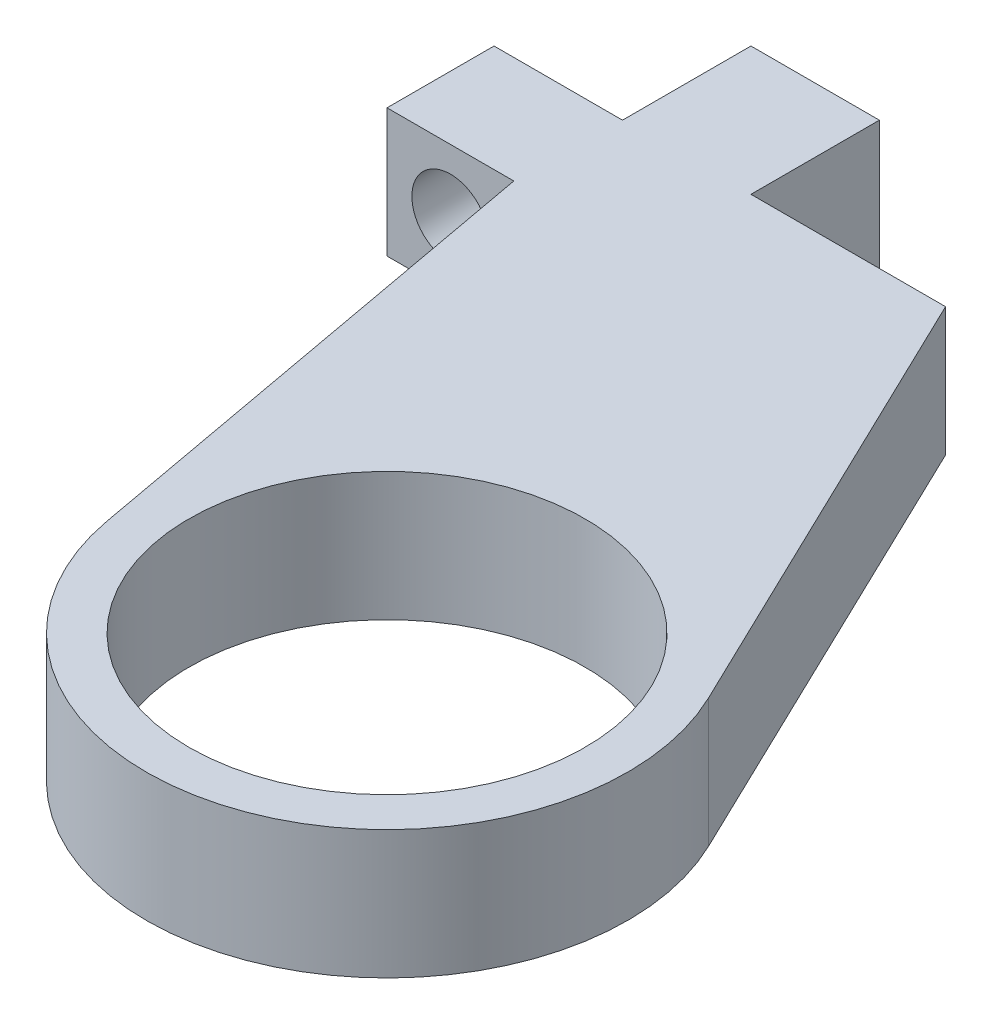
from build123d import *

# Parameters (mm, degrees)
SKETCH1_R           = 9.25
BOSS_EXTRUDE1_DEPTH = 6
SKETCH2_R           = 1.8
CUT_EXTRUDE1_DEPTH  = 12


with BuildPart() as part:
    # Sketch1 → Boss-Extrude1 (new body)
    with BuildSketch(Plane(origin=(0, 0, 0), x_dir=(1, 0, 0), z_dir=(0, 1, 0))):
        with BuildLine():
            Line((-21.25, 26.25), (-15.25, 26.25))
            Line((-15.25, 26.25), (-15.25, 32.25))
            Line((-15.25, 32.25), (-9.25, 32.25))
            Line((-9.25, 32.25), (-9.25, 26.25))
            Line((-9.25, 26.25), (-0.158743734, 26.25))
            Line((-0.158743734, 26.25), (10.135163922, 4.882719763))
            ThreePointArc((10.135163922, 4.882719763), (3.485591088, -10.696408499), (-11.066060992, -2.026029152))
            Line((-11.066060992, -2.026029152), (-15.327551476, 21.25))
            Line((-15.327551476, 21.25), (-21.25, 21.25))
            Line((-21.25, 21.25), (-21.25, 26.25))
        make_face()
        Circle(SKETCH1_R, mode=Mode.SUBTRACT)
    extrude(amount=BOSS_EXTRUDE1_DEPTH)

    # Sketch2 → Cut-Extrude1 (cut, through all)
    with BuildSketch(Plane.XY.offset(-21.25)):
        with Locations((-18.288775738, 3)):
            Circle(SKETCH2_R)
    extrude(amount=-CUT_EXTRUDE1_DEPTH, mode=Mode.SUBTRACT)


solid = part.part
